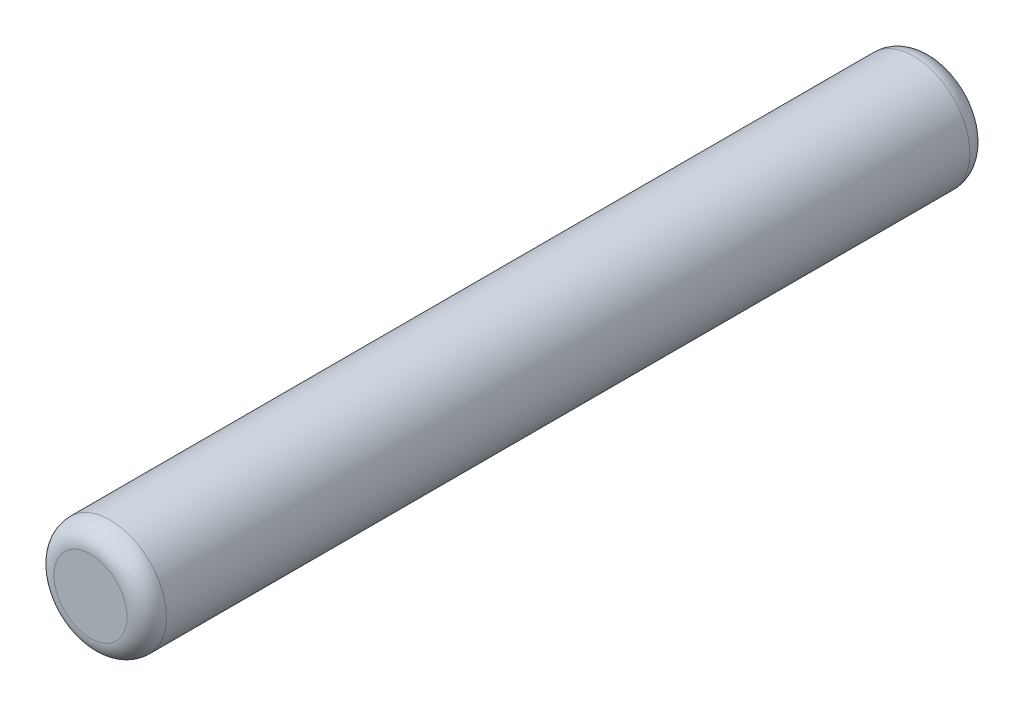
from build123d import *

# Parameters (mm, degrees)
SKETCH1_R           = 1
BOSS_EXTRUDE1_DEPTH = 7.5
FILLET1_R           = 0.35


with BuildPart() as part:
    # Sketch1 → Boss-Extrude1 (new body, symmetric)
    with BuildSketch(Plane.XY):
        Circle(SKETCH1_R)
    extrude(amount=BOSS_EXTRUDE1_DEPTH, both=True)

    # Fillet1
    fillet1_edges = [part.edges().sort_by_distance(p)[0] for p in [
        (-1, 0, -7.5),
        (-1, 0, 7.5),
    ]]
    fillet(fillet1_edges, radius=FILLET1_R)


solid = part.part
